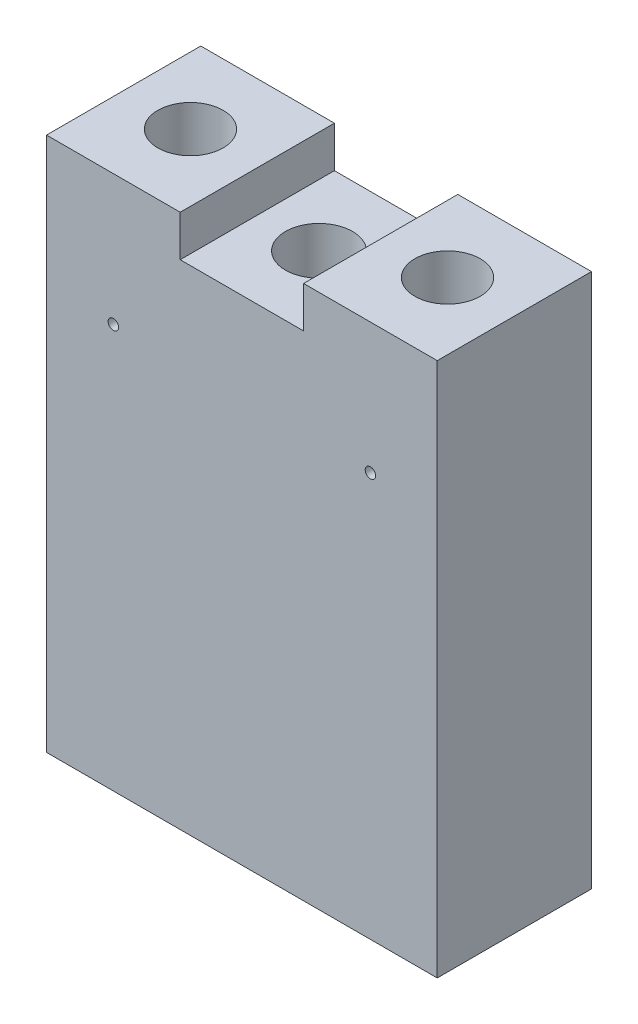
from build123d import *

# Parameters (mm, degrees)
SKETCH1_W               = 38
SKETCH1_H               = 52
EXTRUDE1_DEPTH          = 15
SKETCH3_R               = 3.175
CUT_EXTRUDE2_DEPTH      = 18
SKETCH5_W               = 12
SKETCH5_H               = 15
CUT_EXTRUDE4_DEPTH      = 4
F_1_4_CLEARANCE_HOLE1_D = 6.5278
CUT_EXTRUDE5_REACH      = 17
SKETCH12_R              = 0.508


with BuildPart() as part:
    # Sketch1 → Extrude1 (new body)
    with BuildSketch(Plane.XY):
        with Locations((0, 26)):
            Rectangle(SKETCH1_W, SKETCH1_H)
    extrude(amount=EXTRUDE1_DEPTH)

    # Sketch3 → Cut-Extrude2 (cut)
    with BuildSketch(Plane(origin=(0, 52, 0), x_dir=(-1, 0, 0), z_dir=(0, 1, 0))):
        with Locations(Location((12.5, 7.5, 0), (0, 0, 90))):  # turned: the seam where the file's is
            Circle(SKETCH3_R)
        with Locations(Location((-12.5, 7.5, 0), (0, 0, 270))):  # turned: the seam where the file's is
            Circle(SKETCH3_R)
    extrude(amount=-CUT_EXTRUDE2_DEPTH, mode=Mode.SUBTRACT)

    # Sketch5 → Cut-Extrude4 (cut)
    with BuildSketch(Plane(origin=(0, 52, 0), x_dir=(-1, 0, 0), z_dir=(0, 1, 0))):
        with Locations((0, 7.5)):
            Rectangle(SKETCH5_W, SKETCH5_H)
    extrude(amount=-CUT_EXTRUDE4_DEPTH, mode=Mode.SUBTRACT)

    # 1/4 Clearance Hole1 (through all)
    with Locations(Plane(origin=(0, 48, 0), x_dir=(-1, 0, 0), z_dir=(0, 1, 0))):
        with Locations((0, 7.5)):
            Hole(F_1_4_CLEARANCE_HOLE1_D / 2)

    # Sketch12 → Cut-Extrude5 (cut, up to next)
    with BuildSketch(Plane.XY.offset(15), mode=Mode.PRIVATE) as cut_extrude5_sk1:
        with Locations((-12.5, 39.3)):
            Circle(SKETCH12_R)
    cut_extrude5_tool1 = extrude(cut_extrude5_sk1.sketch, amount=-CUT_EXTRUDE5_REACH, mode=Mode.PRIVATE) & part.part
    add(cut_extrude5_tool1.solids().sort_by_distance((-12.5, 39.3, 15))[0], mode=Mode.SUBTRACT)
    # Sketch12 → Cut-Extrude5 (cut, up to next)
    with BuildSketch(Plane.XY.offset(15), mode=Mode.PRIVATE) as cut_extrude5_sk2:
        with Locations((12.5, 39.3)):
            Circle(SKETCH12_R)
    cut_extrude5_tool2 = extrude(cut_extrude5_sk2.sketch, amount=-CUT_EXTRUDE5_REACH, mode=Mode.PRIVATE) & part.part
    add(cut_extrude5_tool2.solids().sort_by_distance((12.5, 39.3, 15))[0], mode=Mode.SUBTRACT)


solid = part.part
